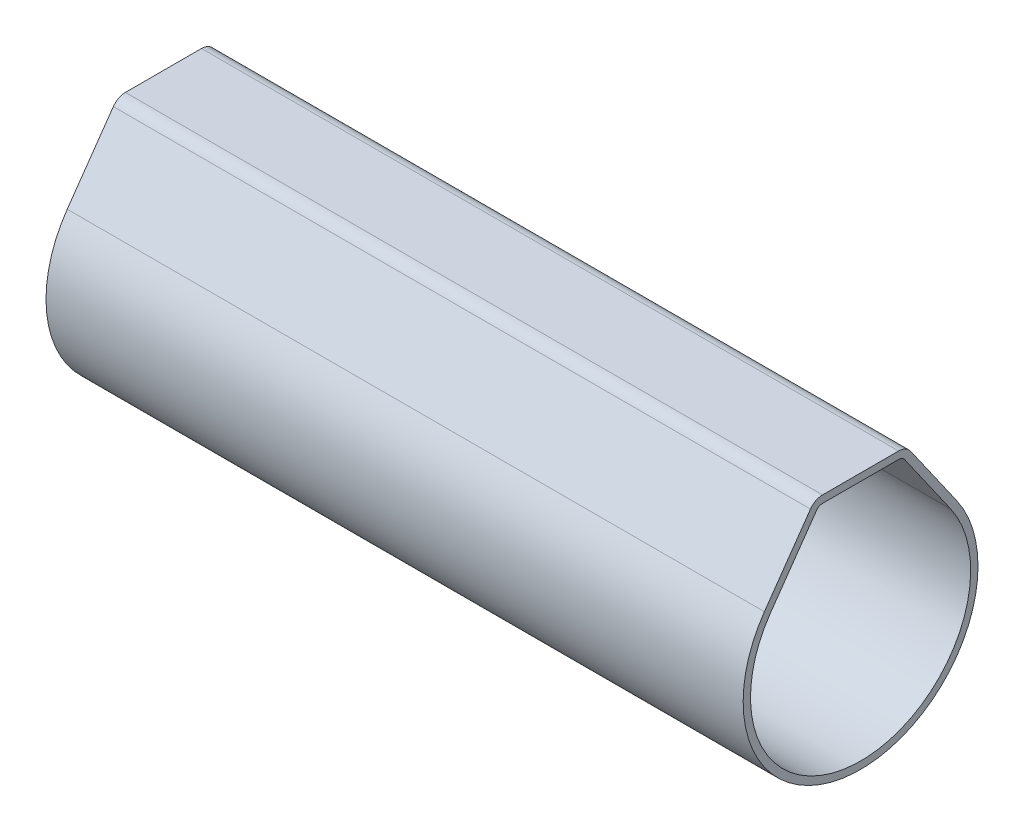
from build123d import *

# Parameters (mm, degrees)
LINEAR_AUSTRAGEN_D_NN1_DEPTH = 95
VERRUNDUNG1_R                = 2
VERRUNDUNG2_R                = 1


with BuildPart() as part:
    # Skizze1 → Linear-Austragen-Dünn1 (new body)
    with BuildSketch(Plane(origin=(0, 0, 0), x_dir=(0, 0, -1), z_dir=(1, 0, 0))):
        with BuildLine():
            Line((-13.106432709, 9.177222982), (-6.228450194, 19))
            Line((-6.228450194, 19), (6.228450194, 19))
            Line((6.228450194, 19), (13.106432709, 9.177222982))
            ThreePointArc((13.106432709, 9.177222982), (0, -16), (-13.106432709, 9.177222982))
        make_face()
        with BuildLine():
            Line((-12.287280664, 8.603646545), (-5.707883144, 18))
            Line((-5.707883144, 18), (5.707883144, 18))
            Line((5.707883144, 18), (12.287280664, 8.603646545))
            ThreePointArc((12.287280664, 8.603646545), (0, -15), (-12.287280664, 8.603646545))
        make_face(mode=Mode.SUBTRACT)
    extrude(amount=LINEAR_AUSTRAGEN_D_NN1_DEPTH)

    # Verrundung1
    verrundung1_edges = [part.edges().sort_by_distance(p)[0] for p in [
        (47.5, 19, 6.228450194),
        (47.5, 19, -6.228450194),
    ]]
    fillet(verrundung1_edges, radius=VERRUNDUNG1_R)

    # Verrundung2
    verrundung2_edges = [part.edges().sort_by_distance(p)[0] for p in [
        (47.5, 18, -5.707883144),
        (47.5, 18, 5.707883144),
    ]]
    fillet(verrundung2_edges, radius=VERRUNDUNG2_R)


solid = part.part
